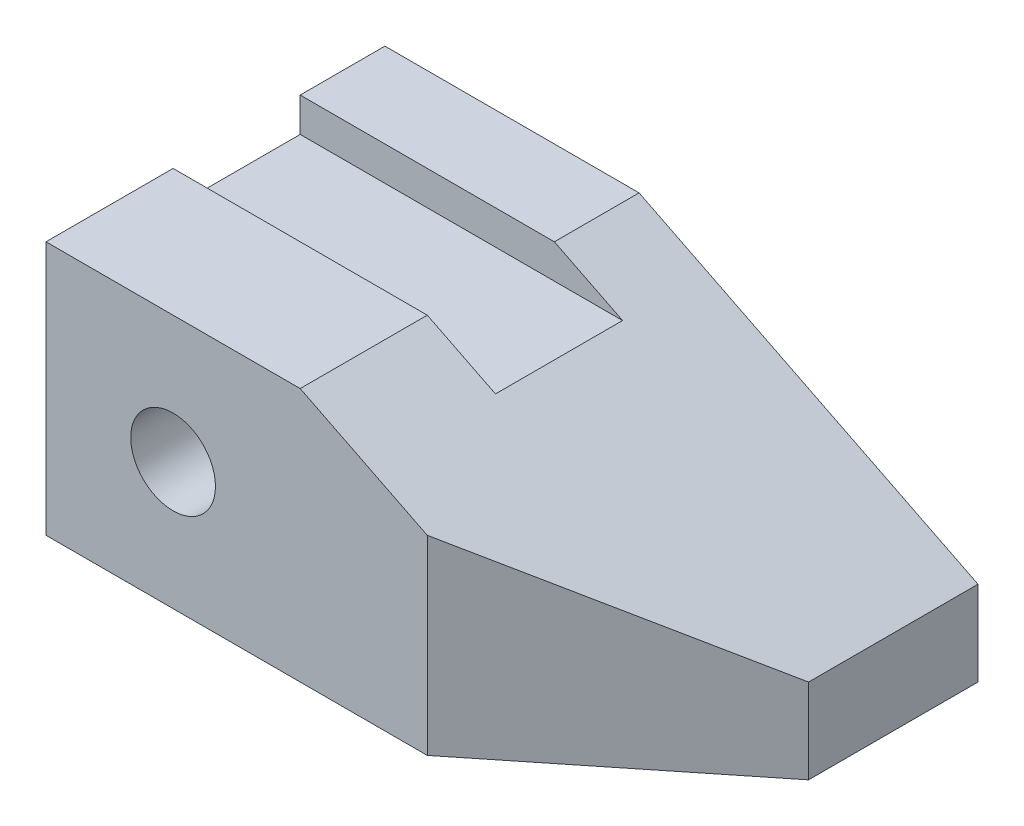
from build123d import *

# Parameters (mm, degrees)
SKETCH1_W           = 70
SKETCH1_H           = 40
BOSS_EXTRUDE1_DEPTH = 30
CUT_EXTRUDE1_DEPTH  = 41
CUT_EXTRUDE2_DEPTH  = 31
SKETCH4_W           = 15
SKETCH4_H           = 4.024531718
CUT_EXTRUDE3_DEPTH  = 71
SKETCH5_R           = 5
CUT_EXTRUDE4_DEPTH  = 41


with BuildPart() as part:
    # Sketch1 → Boss-Extrude1 (new body)
    with BuildSketch(Plane(origin=(0, 0, 0), x_dir=(1, 0, 0), z_dir=(0, 1, 0))):
        with Locations((35, 20)):
            Rectangle(SKETCH1_W, SKETCH1_H)
    extrude(amount=BOSS_EXTRUDE1_DEPTH)

    # Sketch2 → Cut-Extrude1 (cut, through all)
    with BuildSketch(Plane.XY):
        Polygon((70, 30), (30, 30), (70, 10), align=None)
    extrude(amount=-CUT_EXTRUDE1_DEPTH, mode=Mode.SUBTRACT)

    # Sketch3 → Cut-Extrude2 (cut, through all)
    with BuildSketch(Plane(origin=(0, 0, 0), x_dir=(-1, 0, 0), z_dir=(0, -1, 0))):
        Polygon((-70, 0), (-45, 0), (-70, 20), align=None)
    extrude(amount=-CUT_EXTRUDE2_DEPTH, mode=Mode.SUBTRACT)

    # Sketch4 → Cut-Extrude3 (cut, through all)
    with BuildSketch(Plane.ZY):
        with Locations((-22.5, 27.987734141)):
            Rectangle(SKETCH4_W, SKETCH4_H)
    extrude(amount=-CUT_EXTRUDE3_DEPTH, mode=Mode.SUBTRACT)

    # Sketch5 → Cut-Extrude4 (cut, through all)
    with BuildSketch(Plane.XY):
        with Locations((15, 15)):
            Circle(SKETCH5_R)
    extrude(amount=-CUT_EXTRUDE4_DEPTH, mode=Mode.SUBTRACT)


solid = part.part
